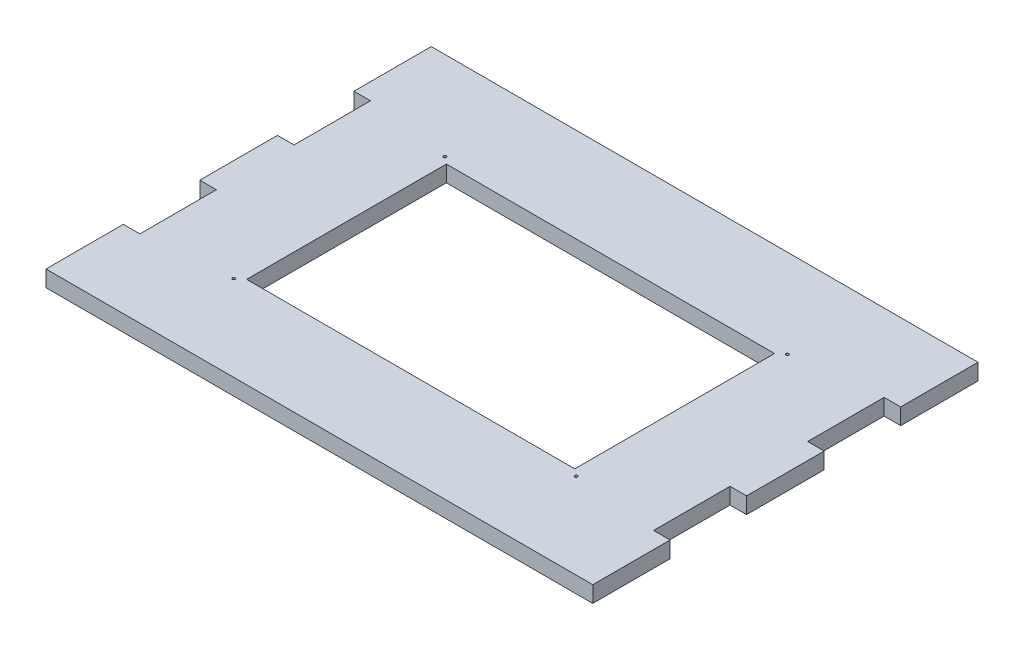
from build123d import *

# Parameters (mm, degrees)
SKETCH3_W           = 192
SKETCH3_H           = 135
BOSS_EXTRUDE1_DEPTH = 5.7
SKETCH9_W           = 115
SKETCH9_H           = 70
CUT_EXTRUDE2_DEPTH  = 47
SKETCH12_R          = 0.5
CUT_EXTRUDE3_DEPTH  = 37
CUT_EXTRUDE4_DEPTH  = 11


with BuildPart() as part:
    # Sketch3 → Boss-Extrude1 (new body)
    with BuildSketch(Plane(origin=(0, 0, 0), x_dir=(1, 0, 0), z_dir=(0, 1, 0))):
        with Locations((90, 53.5)):
            Rectangle(SKETCH3_W, SKETCH3_H)
    extrude(amount=BOSS_EXTRUDE1_DEPTH)

    # Sketch9 → Cut-Extrude2 (cut)
    with BuildSketch(Plane(origin=(0, 0, 0), x_dir=(1, 0, 0), z_dir=(0, 1, 0))):
        with Locations((90, 53)):
            Rectangle(SKETCH9_W, SKETCH9_H)
    extrude(amount=CUT_EXTRUDE2_DEPTH, mode=Mode.SUBTRACT)

    # Sketch12 → Cut-Extrude3 (cut)
    with BuildSketch(Plane(origin=(0, 0, 0), x_dir=(1, 0, 0), z_dir=(0, 1, 0))):
        with Locations((30, 90)):
            Circle(SKETCH12_R)
        with Locations((30, 16)):
            Circle(SKETCH12_R)
        with Locations((150, 16)):
            Circle(SKETCH12_R)
        with Locations((150, 90)):
            Circle(SKETCH12_R)
    extrude(amount=CUT_EXTRUDE3_DEPTH, mode=Mode.SUBTRACT)

    # Sketch13 → Cut-Extrude4 (cut)
    with BuildSketch(Plane(origin=(0, 0, 0), x_dir=(1, 0, 0), z_dir=(0, 1, 0))):
        Polygon((-5.8, 121), (-5.8, 93.9), (0, 93.9), (0, 67.1), (-5.8, 67.1), (-5.8, 39.9), (0, 39.9), (0, 13.1), (-5.8, 13.1), (-5.8, -14), (-9.8, -14), (-9.8, 121), align=None)
        Polygon((189.8, 121), (185.8, 121), (185.8, 93.9), (180, 93.9), (180, 67.1), (185.8, 67.1), (185.8, 39.9), (180, 39.9), (180, 13.1), (185.8, 13.1), (185.8, -14), (189.8, -14), align=None)
    extrude(amount=CUT_EXTRUDE4_DEPTH, mode=Mode.SUBTRACT)


solid = part.part
